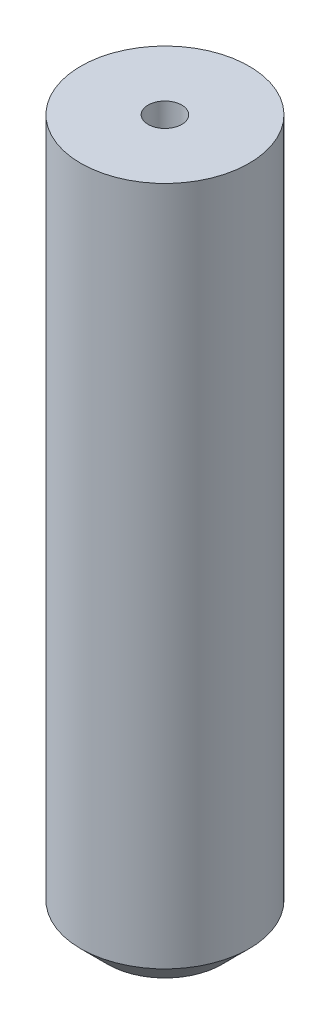
from build123d import *

# Parameters (mm, degrees)
SKETCH1_R           = 12.5
BOSS_EXTRUDE1_DEPTH = 105
SKETCH2_R           = 2.5
CUT_EXTRUDE1_DEPTH  = 105
CHAMFER1_SIZE       = 4


with BuildPart() as part:
    # Sketch1 → Boss-Extrude1 (new body)
    with BuildSketch(Plane(origin=(0, 0, 0), x_dir=(1, 0, 0), z_dir=(0, 1, 0))):
        Circle(SKETCH1_R)
    extrude(amount=BOSS_EXTRUDE1_DEPTH)

    # Sketch2 → Cut-Extrude1 (cut)
    with BuildSketch(Plane(origin=(0, 105, 0), x_dir=(1, 0, 0), z_dir=(0, 1, 0))):
        Circle(SKETCH2_R)
    extrude(amount=-CUT_EXTRUDE1_DEPTH, mode=Mode.SUBTRACT)

    # Chamfer1
    chamfer1_edges = [part.edges().sort_by_distance(p)[0] for p in [
        (-12.5, 0, 0),
    ]]
    chamfer(chamfer1_edges, length=CHAMFER1_SIZE)


solid = part.part
